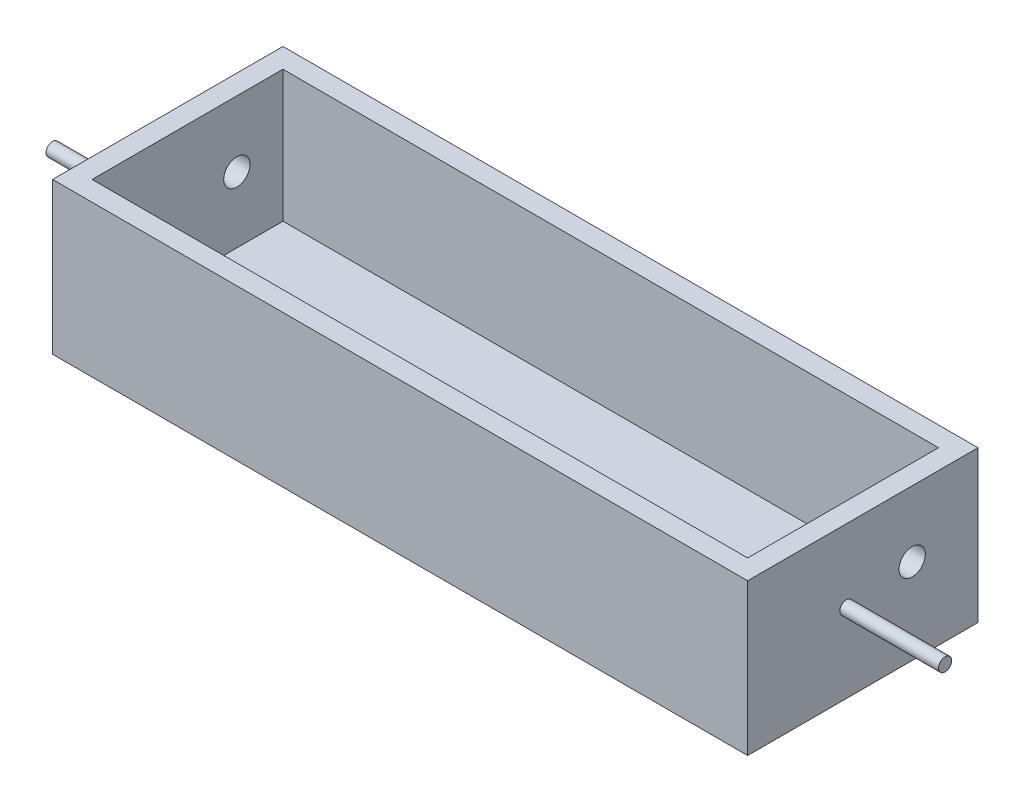
from build123d import *

# Parameters (mm, degrees)
SKETCH_1_W           = 105.6
SKETCH_1_H           = 20
EXTRUDE_1_DEPTH      = 3
SKETCH_10_W          = 105.6
SKETCH_10_H          = 20
SKETCH_10_W_2        = 99.6
SKETCH_10_H_2        = 14
EXTRUDE_2_DEPTH      = 20
SKETCH_11_R          = 2
CUT_EXTRUDE_1_DEPTH  = 110
SKETCH_12_W          = 15
SKETCH_12_H          = 23
EXTRUDE_3_DEPTH      = 105.6
SKETCH_14_W          = 99.6
SKETCH_14_H          = 15
CUT_EXTRUDE_2_DEPTH  = 20
CUT_EXTRUDE_3_DEPTH  = 20
SKETCH_17_R          = 1
EXTRUDE_4_DEPTH      = 15
EXTRUDE_4_DEPTH_BACK = 120.6
SKETCH_19_W          = 99.6
SKETCH_19_H          = 29
CUT_EXTRUDE_4_DEPTH  = 10


with BuildPart() as part:
    # 草图1 → 凸台-拉伸1 (new body)
    with BuildSketch(Plane(origin=(0, 0, 0), x_dir=(1, 0, 0), z_dir=(0, 1, 0))):
        Rectangle(SKETCH_1_W, SKETCH_1_H)
    extrude(amount=EXTRUDE_1_DEPTH)

    # 草图10 → 凸台-拉伸2 (add)
    with BuildSketch(Plane(origin=(0, 3, 0), x_dir=(1, 0, 0), z_dir=(0, 1, 0))):
        Rectangle(SKETCH_10_W, SKETCH_10_H)
        Rectangle(SKETCH_10_W_2, SKETCH_10_H_2, mode=Mode.SUBTRACT)
    extrude(amount=EXTRUDE_2_DEPTH)

    # 草图11 → 切除-拉伸1 (cut)
    with BuildSketch(Plane.ZY.offset(52.8)):
        with Locations((0, 13)):
            Circle(SKETCH_11_R)
    extrude(amount=-CUT_EXTRUDE_1_DEPTH, mode=Mode.SUBTRACT)

    # 草图12 → 凸台-拉伸3 (add)
    with BuildSketch(Plane.ZY.offset(52.8)):
        with Locations((17.5, 11.5)):
            Rectangle(SKETCH_12_W, SKETCH_12_H)
    extrude(amount=-EXTRUDE_3_DEPTH)

    # 草图14 → 切除-拉伸2 (cut)
    with BuildSketch(Plane(origin=(0, 23, 0), x_dir=(1, 0, 0), z_dir=(0, 1, 0))):
        with Locations((0, -14.5)):
            Rectangle(SKETCH_14_W, SKETCH_14_H)
    extrude(amount=-CUT_EXTRUDE_2_DEPTH, mode=Mode.SUBTRACT)

    # 草图16 → 切除-拉伸3 (cut)
    with BuildSketch(Plane.XZ):
        with BuildLine():
            ThreePointArc((-33.5, 7.719862672), (-34.671572875, 10.548289796), (-37.5, 11.719862672))
            Line((-37.5, 11.719862672), (-37.5, 3.719862672))
            ThreePointArc((-37.5, 3.719862672), (-34.671572875, 4.891435547), (-33.5, 7.719862672))
        make_face()
        with BuildLine():
            Line((-37.5, 3.719862672), (-37.5, 11.719862672))
            ThreePointArc((-37.5, 11.719862672), (-41.5, 7.719862672), (-37.5, 3.719862672))
        make_face()
        with BuildLine():
            ThreePointArc((41.5, 7.5), (40.328427125, 10.328427125), (37.5, 11.5))
            Line((37.5, 11.5), (37.5, 3.5))
            ThreePointArc((37.5, 3.5), (40.328427125, 4.671572875), (41.5, 7.5))
        make_face()
        with BuildLine():
            Line((37.5, 3.5), (37.5, 11.5))
            ThreePointArc((37.5, 11.5), (33.5, 7.5), (37.5, 3.5))
        make_face()
    extrude(amount=-CUT_EXTRUDE_3_DEPTH, mode=Mode.SUBTRACT)

    # 草图17 → 凸台-拉伸4 (add, two sides)
    with BuildSketch(Plane.ZY.offset(52.8)) as extrude_4_sk:
        with Locations((10, 12)):
            Circle(SKETCH_17_R)
    extrude(amount=EXTRUDE_4_DEPTH)
    extrude(extrude_4_sk.sketch, amount=-EXTRUDE_4_DEPTH_BACK)

    # 草图19 → 切除-拉伸4 (cut)
    with BuildSketch(Plane(origin=(0, 3, 0), x_dir=(1, 0, 0), z_dir=(0, 1, 0))):
        with Locations((0, -7.5)):
            Rectangle(SKETCH_19_W, SKETCH_19_H)
    extrude(amount=CUT_EXTRUDE_4_DEPTH, mode=Mode.SUBTRACT)


solid = part.part
